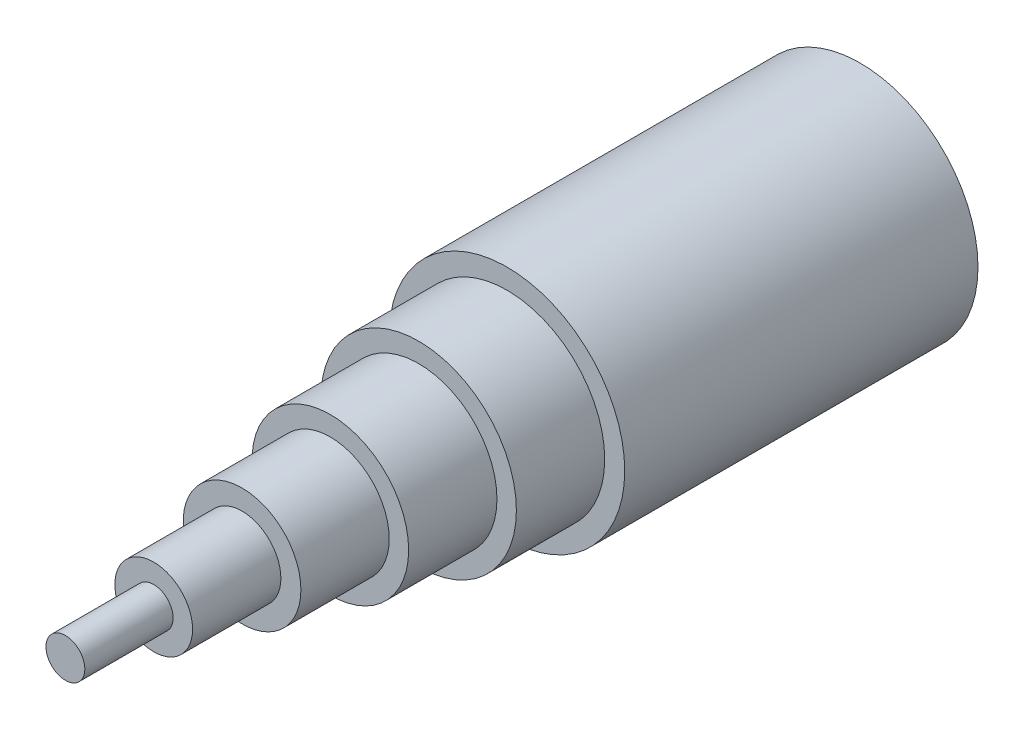
from build123d import *

# Parameters (mm, degrees)
SKETCH1_R           = 1
BOSS_EXTRUDE1_DEPTH = 3
SKETCH2_R           = 0.33
SKETCH2_R_2         = 0.165
BOSS_EXTRUDE2_DEPTH = 3
SKETCH2_3_R         = 0.5
SKETCH2_3_R_2       = 0.33
BOSS_EXTRUDE3_DEPTH = 2.25
SKETCH2_4_R         = 0.665
SKETCH2_4_R_2       = 0.5
BOSS_EXTRUDE4_DEPTH = 1.5
SKETCH2_6_R         = 0.83
SKETCH2_6_R_2       = 0.665
BOSS_EXTRUDE6_DEPTH = 0.75
SKETCH2_7_R         = 0.165
BOSS_EXTRUDE7_DEPTH = 3.75


with BuildPart() as part:
    # Sketch1 → Boss-Extrude1 (new body)
    with BuildSketch(Plane.XY):
        Circle(SKETCH1_R)
    extrude(amount=BOSS_EXTRUDE1_DEPTH)

    # Sketch2 → Boss-Extrude2 (add)
    with BuildSketch(Plane.XY.offset(3)):
        Circle(SKETCH2_R)
        Circle(SKETCH2_R_2, mode=Mode.SUBTRACT)
    extrude(amount=BOSS_EXTRUDE2_DEPTH)

    # Sketch2_3 → Boss-Extrude3 (add)
    with BuildSketch(Plane.XY.offset(3)):
        Circle(SKETCH2_3_R)
        Circle(SKETCH2_3_R_2, mode=Mode.SUBTRACT)
    extrude(amount=BOSS_EXTRUDE3_DEPTH)

    # Sketch2_4 → Boss-Extrude4 (add)
    with BuildSketch(Plane.XY.offset(3)):
        Circle(SKETCH2_4_R)
        Circle(SKETCH2_4_R_2, mode=Mode.SUBTRACT)
    extrude(amount=BOSS_EXTRUDE4_DEPTH)

    # Sketch2_6 → Boss-Extrude6 (add)
    with BuildSketch(Plane.XY.offset(3)):
        Circle(SKETCH2_6_R)
        Circle(SKETCH2_6_R_2, mode=Mode.SUBTRACT)
    extrude(amount=BOSS_EXTRUDE6_DEPTH)

    # Sketch2_7 → Boss-Extrude7 (add)
    with BuildSketch(Plane.XY.offset(3)):
        Circle(SKETCH2_7_R)
    extrude(amount=BOSS_EXTRUDE7_DEPTH)


solid = part.part
